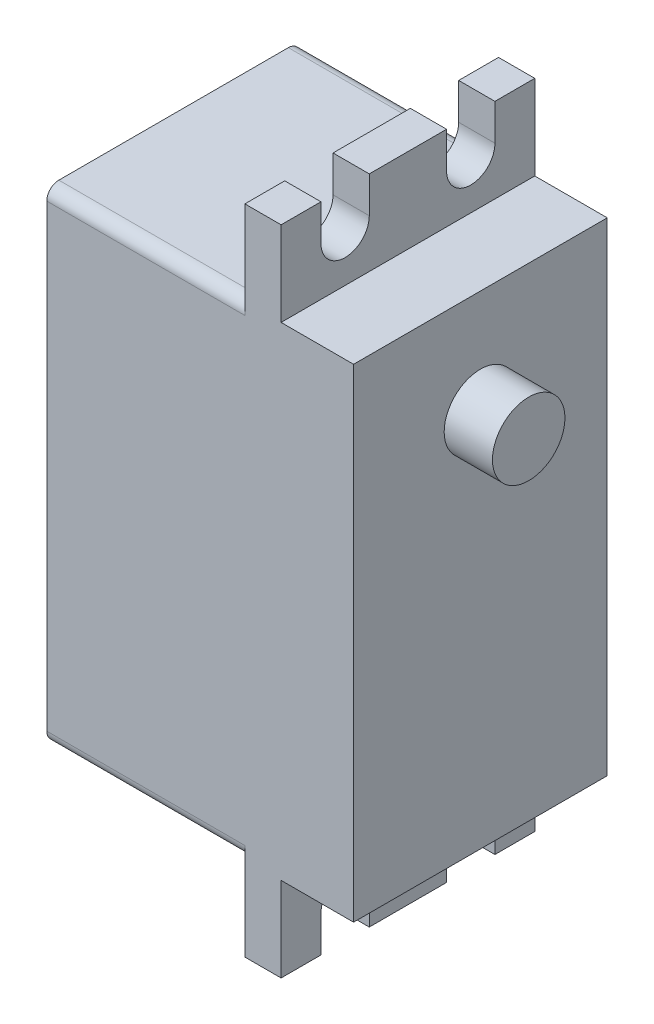
from build123d import *

# Parameters (mm, degrees)
SKETCH1_W            = 21
SKETCH1_H            = 40
BOSS_EXTRUDE1_DEPTH  = 16.4
SKETCH2_W            = 21
SKETCH2_H            = 54
BOSS_EXTRUDE2_DEPTH  = 3
CUT_EXTRUDE1_DEPTH   = 3
MIRROR2_COPY_1_DEPTH = 3
SKETCH5_W            = 21
SKETCH5_H            = 40
BOSS_EXTRUDE4_DEPTH  = 6
SKETCH6_R            = 3
BOSS_EXTRUDE5_DEPTH  = 0.01
FILLET1_R            = 1
SKETCH9_R            = 3
BOSS_EXTRUDE7_DEPTH  = 3.9878


with BuildPart() as part:
    # Sketch1 → Boss-Extrude1 (new body)
    with BuildSketch(Plane(origin=(0, 0, 0), x_dir=(0, 0, -1), z_dir=(1, 0, 0))):
        Rectangle(SKETCH1_W, SKETCH1_H)
    extrude(amount=BOSS_EXTRUDE1_DEPTH)

    # Sketch2 → Boss-Extrude2 (add)
    with BuildSketch(Plane(origin=(16.4, 0, 0), x_dir=(0, 0, -1), z_dir=(1, 0, 0))):
        Rectangle(SKETCH2_W, SKETCH2_H)
    extrude(amount=BOSS_EXTRUDE2_DEPTH)

    # Sketch3 → Cut-Extrude1 (cut)
    with BuildSketch(Plane(origin=(19.4, 0, 0), x_dir=(0, 0, -1), z_dir=(1, 0, 0))):
        with BuildLine():
            Line((-3.200000014, 24), (-3.200000014, 27))
            Line((-3.200000014, 27), (-7.200000014, 27))
            Line((-7.200000014, 27), (-7.200000014, 24))
            ThreePointArc((-7.200000014, 24), (-5.200000014, 22), (-3.200000014, 24))
        make_face()
    cut_extrude1 = extrude(amount=-CUT_EXTRUDE1_DEPTH, mode=Mode.SUBTRACT)

    # Mirror1: Cut-Extrude1 across plane
    add(cut_extrude1.mirror(Plane.XY), mode=Mode.SUBTRACT)

    # Mirror2: Cut-Extrude1 across plane
    add(cut_extrude1.mirror(Plane.ZX), mode=Mode.SUBTRACT)

    # Mirror2 copy 1 sketch → Mirror2 copy 1 (cut)
    with BuildSketch(Plane(origin=(19.4, 0, 0), x_dir=(0, 0, 1), z_dir=(1, 0, 0))):
        with BuildLine():
            Line((-3.200000014, 24), (-3.200000014, 27))
            Line((-3.200000014, 27), (-7.200000014, 27))
            Line((-7.200000014, 27), (-7.200000014, 24))
            ThreePointArc((-7.200000014, 24), (-5.200000014, 22), (-3.200000014, 24))
        make_face()
    extrude(amount=-MIRROR2_COPY_1_DEPTH, mode=Mode.SUBTRACT)

    # Sketch5 → Boss-Extrude4 (add)
    with BuildSketch(Plane(origin=(19.4, 0, 0), x_dir=(0, 0, -1), z_dir=(1, 0, 0))):
        Rectangle(SKETCH5_W, SKETCH5_H)
    extrude(amount=BOSS_EXTRUDE4_DEPTH)

    # Sketch6 → Boss-Extrude5 (add)
    with BuildSketch(Plane(origin=(25.4, 0, 0), x_dir=(0, 0, -1), z_dir=(1, 0, 0))):
        with Locations((0, 11.4)):
            Circle(SKETCH6_R)
    extrude(amount=BOSS_EXTRUDE5_DEPTH)

    # Fillet1
    fillet1_edges = [part.edges().sort_by_distance(p)[0] for p in [
        (8.2, -20, -10.5),
        (8.2, -20, 10.5),
        (8.2, 20, 10.5),
        (8.2, 20, -10.5),
    ]]
    fillet(fillet1_edges, radius=FILLET1_R)

    # Sketch9 → Boss-Extrude7 (add)
    with BuildSketch(Plane(origin=(25.41, 0, 0), x_dir=(0, 0, -1), z_dir=(1, 0, 0))):
        with Locations((0, 11.4)):
            Circle(SKETCH9_R)
    extrude(amount=BOSS_EXTRUDE7_DEPTH)


solid = part.part
